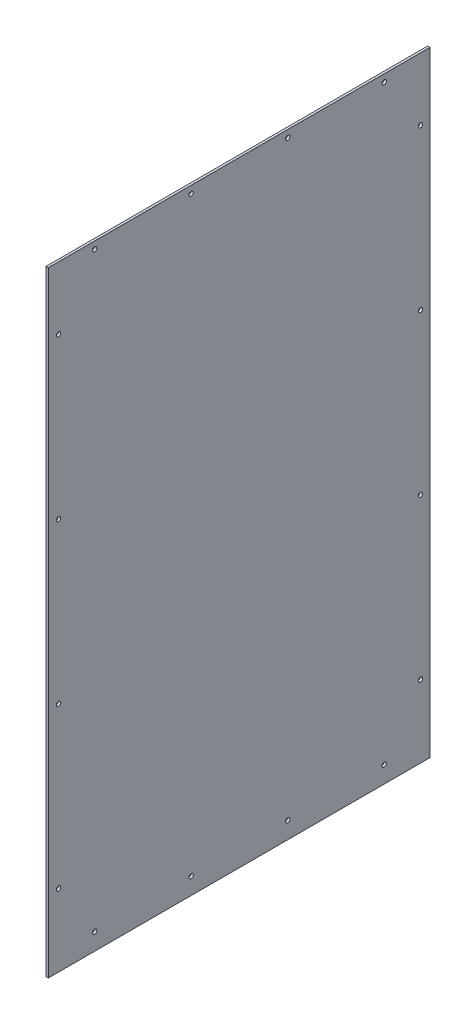
from build123d import *

# Parameters (mm, degrees)
SKETCH1_W                 = 502.3866
SKETCH1_H                 = 809.7266
SIDEPANEL_DEPTH           = 3.0734
SKETCH2_R                 = 2.8956
TOPBOTTOMHOLEMASTER_DEPTH = 4.0734
LPATTERN1_COUNT           = 4
LPATTERN1_PITCH           = 127.067733333
SKETCH3_R                 = 2.8956
REARHOLESMASTER_DEPTH     = 4.0734
LPATTERN2_COUNT           = 4
LPATTERN2_PITCH           = 210.574466667
CUT_EXTRUDE1_DEPTH        = 2.54


with BuildPart() as part:
    # Sketch1 → SidePanel (new body)
    with BuildSketch(Plane(origin=(0, 0, 0), x_dir=(0, 0, -1), z_dir=(1, 0, 0))):
        Rectangle(SKETCH1_W, SKETCH1_H)
    extrude(amount=SIDEPANEL_DEPTH)

    # Sketch2 → TopBottomHoleMaster (cut, through all)
    with BuildSketch(Plane(origin=(3.0734, 0, 0), x_dir=(0, 0, -1), z_dir=(1, 0, 0))):
        with Locations((190.9699, 395.3383)):
            Circle(SKETCH2_R)
        with Locations((190.9699, -382.6383)):
            Circle(SKETCH2_R)
    topbottomholemaster = extrude(amount=-TOPBOTTOMHOLEMASTER_DEPTH, mode=Mode.SUBTRACT)

    # LPattern1: TopBottomHoleMaster ×4
    with Locations(*[(0, 0, i * LPATTERN1_PITCH) for i in range(1, LPATTERN1_COUNT)]):
        add(topbottomholemaster, mode=Mode.SUBTRACT)

    # Sketch3 → RearHolesMaster (cut, through all)
    with BuildSketch(Plane(origin=(3.0734, 0, 0), x_dir=(0, 0, -1), z_dir=(1, 0, 0))):
        with Locations((-237.8583, 322.2117)):
            Circle(SKETCH3_R)
        with Locations((238.5949, 322.2117)):
            Circle(SKETCH3_R)
    rearholesmaster = extrude(amount=-REARHOLESMASTER_DEPTH, mode=Mode.SUBTRACT)

    # LPattern2: RearHolesMaster ×4
    with Locations(*[(0, -i * LPATTERN2_PITCH, 0) for i in range(1, LPATTERN2_COUNT)]):
        add(rearholesmaster, mode=Mode.SUBTRACT)

    # Sketch4 → Cut-Extrude1 (cut)
    with BuildSketch(Plane.ZY):
        Polygon((-238.257543072, -385.5339), (-239.273543072, -385.5339), (-239.273543072, -384.2639), (-239.781543072, -384.2639), (-238.765543072, -382.9939), (-237.749543072, -384.2639), (-238.257543072, -384.2639), align=None)
    extrude(amount=-CUT_EXTRUDE1_DEPTH, mode=Mode.SUBTRACT)


solid = part.part
